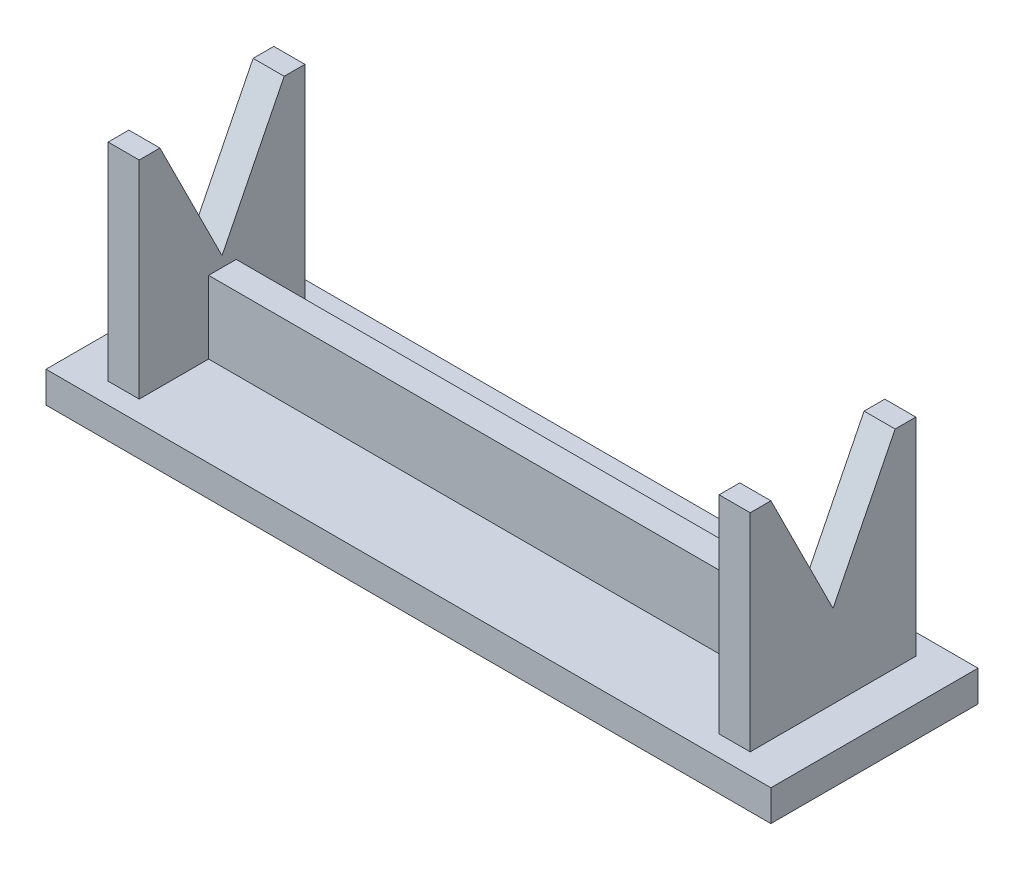
from build123d import *

# Parameters (mm, degrees)
SKETCH_219_W                = 70
SKETCH_219_H                = 20
EXTRUDE_370_DEPTH           = 3
SKETCH_424_W                = 3
SKETCH_424_H                = 16
EXTRUDE_647_DEPTH           = 20
CUT_EXTRUDE_897_DEPTH       = 5
CUT_EXTRUDE_897_DEPTH_BACK  = 3
SKETCH_8_W                  = 3
SKETCH_8_H                  = 16
EXTRUDE_1252_DEPTH          = 20
CUT_EXTRUDE_1518_DEPTH      = 64
CUT_EXTRUDE_1518_DEPTH_BACK = 3
SKETCH_11_W                 = 56
SKETCH_11_H                 = 2.665153407
EXTRUDE_1792_DEPTH          = 7


with BuildPart() as part:
    # Sketch 219 → Extrude 370 (new body)
    with BuildSketch(Plane(origin=(0, 0, 0), x_dir=(1, 0, 0), z_dir=(0, 1, 0))):
        with Locations((35, 10)):
            Rectangle(SKETCH_219_W, SKETCH_219_H)
    extrude(amount=EXTRUDE_370_DEPTH)

    # Sketch 424 → Extrude 647 (add)
    with BuildSketch(Plane(origin=(0, 3, 0), x_dir=(1, 0, 0), z_dir=(0, 1, 0))):
        with Locations((5.5, 10)):
            Rectangle(SKETCH_424_W, SKETCH_424_H)
    extrude(amount=EXTRUDE_647_DEPTH)

    # Sketch 702 → Cut-Extrude 897 (cut, two sides)
    with BuildSketch(Plane.ZY.offset(-4)) as cut_extrude_897_sk:
        Polygon((-45.532064127, 82.064128255), (-16, 23), (-10, 11), (-4, 23), (25.532064127, 82.064128255), (25.532064127, 214.135534064), (-45.532064127, 214.135534064), align=None)
    extrude(amount=CUT_EXTRUDE_897_DEPTH, mode=Mode.SUBTRACT)
    extrude(cut_extrude_897_sk.sketch, amount=-CUT_EXTRUDE_897_DEPTH_BACK, mode=Mode.SUBTRACT)

    # Эскиз8 → Extrude 1252 (add)
    with BuildSketch(Plane(origin=(31.408501121, 3, 2.625790974), x_dir=(1, 0, 0), z_dir=(0, 1, 0))):
        with Locations((33.091498879, 12.625790974)):
            Rectangle(SKETCH_8_W, SKETCH_8_H)
    extrude(amount=EXTRUDE_1252_DEPTH)

    # Эскиз10 → Cut-Extrude 1518 (cut, two sides)
    with BuildSketch(Plane(origin=(63, 0, 2.625790974), x_dir=(0, 0, 1), z_dir=(-1, 0, 0))) as cut_extrude_1518_sk:
        Polygon((-48.157855101, 82.064128255), (-18.625790974, 23), (-12.625790974, 11), (-6.625790974, 23), (22.906273154, 82.064128255), (22.906273154, 214.135534064), (-48.157855101, 214.135534064), align=None)
    extrude(amount=CUT_EXTRUDE_1518_DEPTH, mode=Mode.SUBTRACT)
    extrude(cut_extrude_1518_sk.sketch, amount=-CUT_EXTRUDE_1518_DEPTH_BACK, mode=Mode.SUBTRACT)

    # Эскиз11 → Extrude 1792 (add)
    with BuildSketch(Plane(origin=(0, 3, 0), x_dir=(1, 0, 0), z_dir=(0, 1, 0))):
        with Locations((35, 10.036015586)):
            Rectangle(SKETCH_11_W, SKETCH_11_H)
    extrude(amount=EXTRUDE_1792_DEPTH)


solid = part.part
